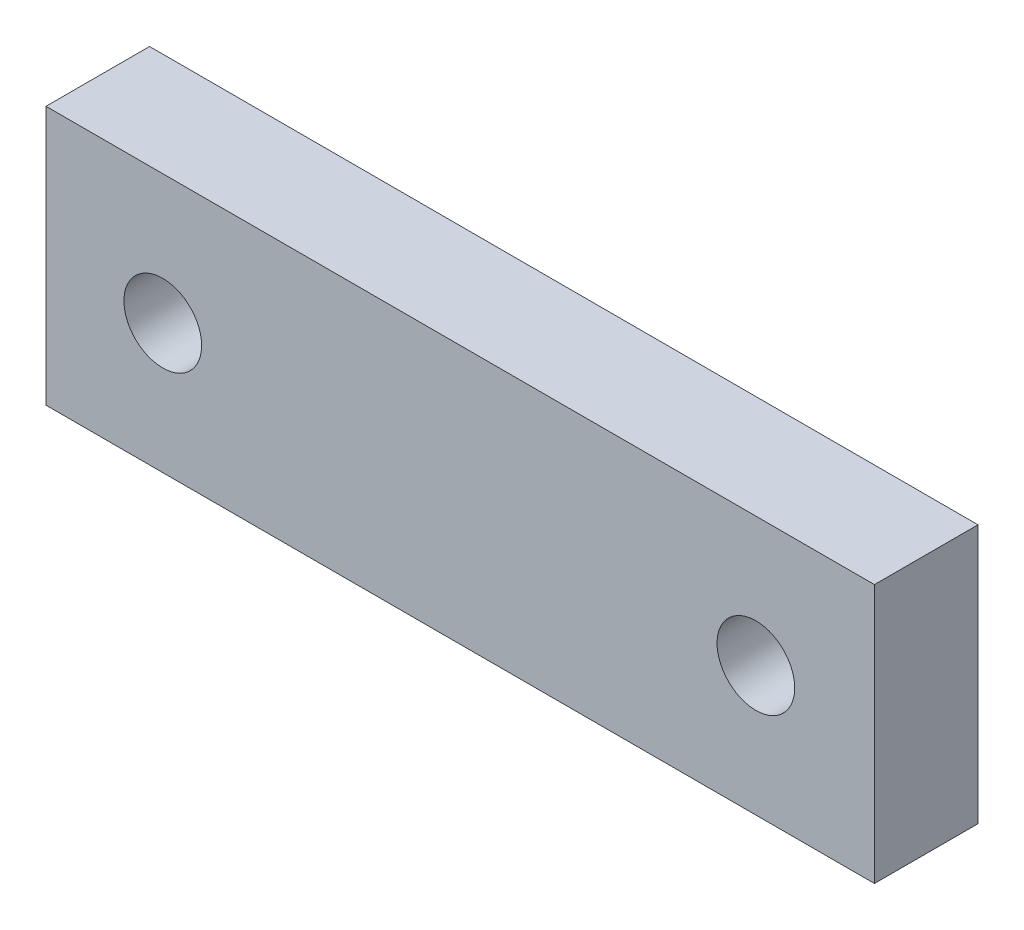
from build123d import *

# Parameters (mm, degrees)
ESBO_O1_W                = 32
ESBO_O1_H                = 10
RESSALTO_EXTRUS_O1_DEPTH = 4
ESBO_O2_R                = 1.5
CORTE_EXTRUS_O1_DEPTH    = 4


with BuildPart() as part:
    # Esboço1 → Ressalto-extrusão1 (new body)
    with BuildSketch(Plane.XY):
        with Locations((16, -5)):
            Rectangle(ESBO_O1_W, ESBO_O1_H)
    extrude(amount=RESSALTO_EXTRUS_O1_DEPTH)

    # Esboço2 → Corte-extrusão1 (cut)
    with BuildSketch(Plane.XY.offset(4)):
        with Locations((4.51, -5)):
            Circle(ESBO_O2_R)
        with Locations((27.42, -5)):
            Circle(ESBO_O2_R)
    extrude(amount=-CORTE_EXTRUS_O1_DEPTH, mode=Mode.SUBTRACT)


solid = part.part
